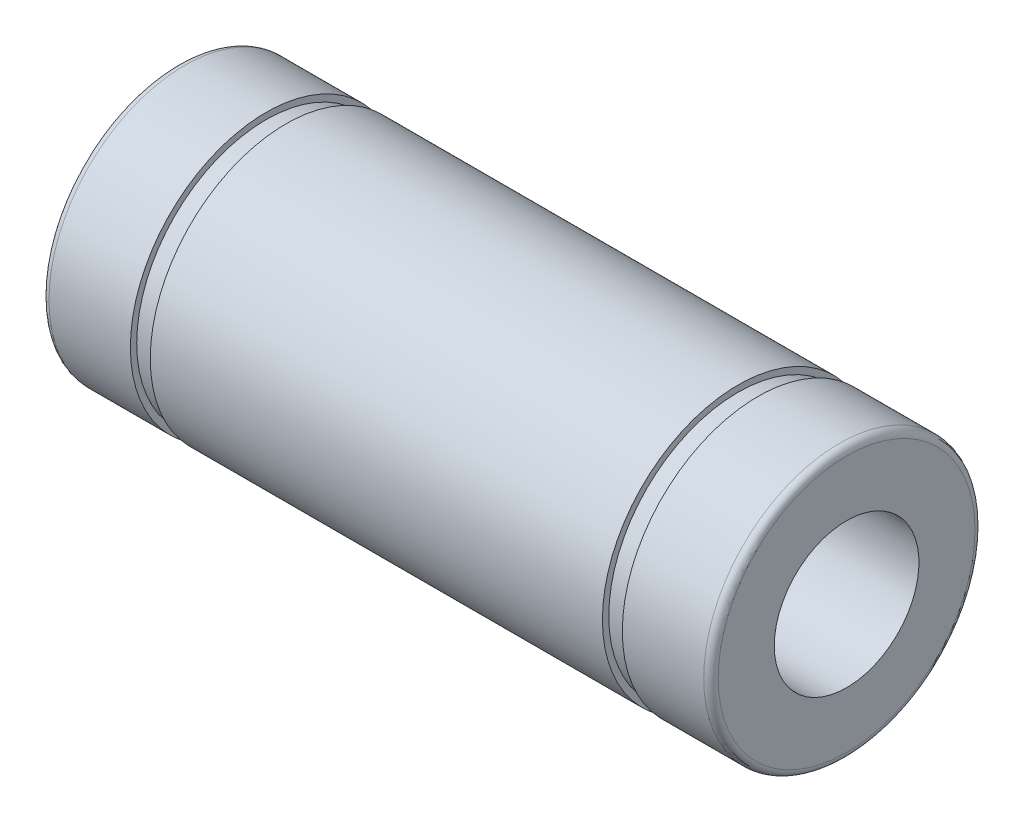
from build123d import *


with BuildPart() as part:
    # Sketch1 → Revolve1 (revolve)
    with BuildSketch(Plane.XY):
        with BuildLine():
            Line((-18.5, 7.1), (-18.5, 4))
            Line((-18.5, 4), (18.5, 4))
            Line((18.5, 4), (18.5, 7.1))
            ThreePointArc((18.5, 7.1), (18.382842712, 7.382842712), (18.1, 7.5))
            Line((18.1, 7.5), (13.6, 7.5))
            Line((13.6, 7.5), (13.6, 7.15))
            Line((13.6, 7.15), (12.5, 7.15))
            Line((12.5, 7.15), (12.5, 7.5))
            Line((12.5, 7.5), (-12.5, 7.5))
            Line((-12.5, 7.5), (-12.5, 7.15))
            Line((-12.5, 7.15), (-13.6, 7.15))
            Line((-13.6, 7.15), (-13.6, 7.5))
            Line((-13.6, 7.5), (-18.1, 7.5))
            ThreePointArc((-18.1, 7.5), (-18.382842712, 7.382842712), (-18.5, 7.1))
        make_face()
    revolve(axis=Axis((18.5, 0, 0), (-1, 0, 0)))


solid = part.part
